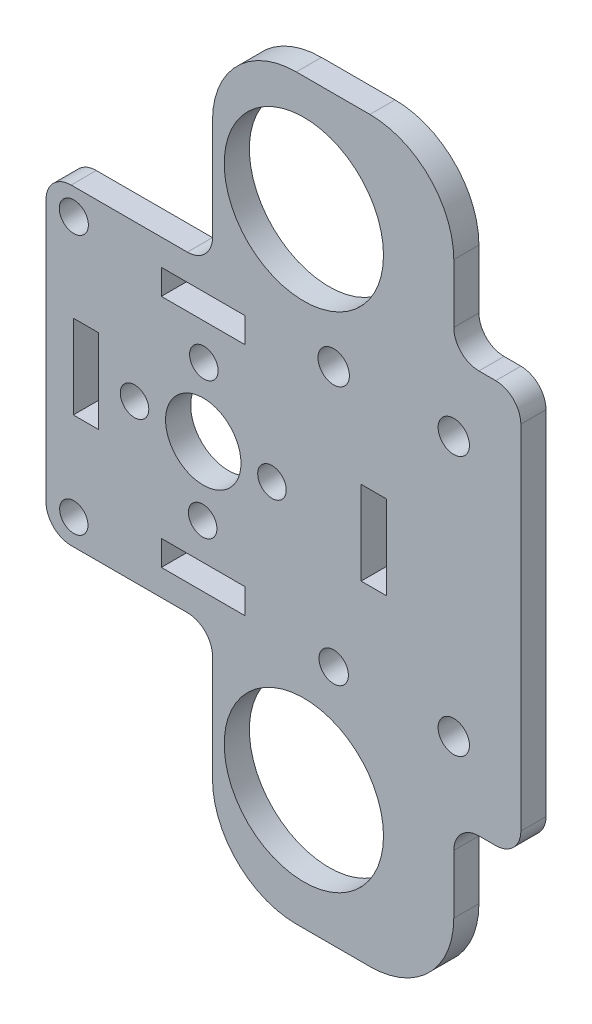
from build123d import *

# Parameters (mm, degrees)
SKETCH1_R           = 1.737885662
SKETCH1_R_2         = 1.873200063
SKETCH1_R_3         = 1.690089146
SKETCH1_R_4         = 1.754205974
SKETCH1_R_5         = 1.7
SKETCH1_R_6         = 4.5
SKETCH1_R_7         = 1.87
SKETCH1_R_8         = 9.5
SKETCH1_W           = 3
SKETCH1_H           = 10
SKETCH1_W_2         = 10
SKETCH1_H_2         = 3
BOSS_EXTRUDE1_DEPTH = 3
FILLET1_R           = 3
FILLET2_R           = 10


with BuildPart() as part:
    # Sketch1 → Boss-Extrude1 (new body)
    with BuildSketch(Plane.XY):
        Polygon((147.061964125, -92.970138098), (147.061964125, -71.856515964), (147.061964125, -67.856515964), (175.843347401, -67.856515964), (175.843347401, -87.856515964), (183.843347401, -87.856515964), (183.843347401, -135.887076434), (175.843347401, -135.887076434), (175.843347401, -155.887076434), (147.061964125, -155.887076434), (147.061964125, -151.887076434), (147.061964125, -130.215533927), (127.203791419, -130.215533927), (127.203791419, -111.591712302), (127.203791419, -92.970138098), align=None)
        with Locations((130.520049527, -96.082032258)):
            Circle(SKETCH1_R, mode=Mode.SUBTRACT)
        with Locations((161.520049527, -96.082032258)):
            Circle(SKETCH1_R_2, mode=Mode.SUBTRACT)
        with Locations((130.520049527, -127.114221831)):
            Circle(SKETCH1_R_3, mode=Mode.SUBTRACT)
        with Locations((161.520049527, -127.082032258)):
            Circle(SKETCH1_R_4, mode=Mode.SUBTRACT)
        with Locations((154.157584865, -111.662272701)):
            Circle(SKETCH1_R_5, mode=Mode.SUBTRACT)
        with Locations((145.89014032, -119.788596448)):
            Circle(SKETCH1_R_5, mode=Mode.SUBTRACT)
        with Locations((137.763816574, -111.521151903)):
            Circle(SKETCH1_R_5, mode=Mode.SUBTRACT)
        with Locations((146.031261118, -103.394828157)):
            Circle(SKETCH1_R_5, mode=Mode.SUBTRACT)
        with Locations((145.960700719, -111.591712302)):
            Circle(SKETCH1_R_6, mode=Mode.SUBTRACT)
        with Locations((175.843347401, -96.114221831)):
            Circle(SKETCH1_R_7, mode=Mode.SUBTRACT)
        with Locations((157.960700719, -81.591712302)):
            Circle(SKETCH1_R_8, mode=Mode.SUBTRACT)
        with Locations((157.960700719, -141.591712302)):
            Circle(SKETCH1_R_8, mode=Mode.SUBTRACT)
        with Locations((175.843347401, -127.114221831)):
            Circle(SKETCH1_R_7, mode=Mode.SUBTRACT)
        with Locations((131.960700719, -111.591712302)):
            Rectangle(SKETCH1_W, SKETCH1_H, mode=Mode.SUBTRACT)
        with Locations((145.960700719, -97.591712302)):
            Rectangle(SKETCH1_W_2, SKETCH1_H_2, mode=Mode.SUBTRACT)
        with Locations((145.960700719, -125.591712302)):
            Rectangle(SKETCH1_W_2, SKETCH1_H_2, mode=Mode.SUBTRACT)
        with Locations((166.293610901, -111.591712302)):
            Rectangle(SKETCH1_W, SKETCH1_H, mode=Mode.SUBTRACT)
    extrude(amount=BOSS_EXTRUDE1_DEPTH)

    # Fillet1
    fillet1_edges = [part.edges().sort_by_distance(p)[0] for p in [
        (175.843347401, -87.856515964, 1.5),
        (183.843347401, -87.856515964, 1.5),
        (183.843347401, -135.887076434, 1.5),
        (175.843347401, -135.887076434, 1.5),
        (147.061964125, -130.215533927, 1.5),
        (127.203791419, -130.215533927, 1.5),
        (127.203791419, -92.970138098, 1.5),
        (147.061964125, -92.970138098, 1.5),
    ]]
    fillet(fillet1_edges, radius=FILLET1_R)

    # Fillet2
    fillet2_edges = [part.edges().sort_by_distance(p)[0] for p in [
        (147.061964125, -67.856515964, 1.5),
        (175.843347401, -67.856515964, 1.5),
        (175.843347401, -155.887076434, 1.5),
        (147.061964125, -155.887076434, 1.5),
    ]]
    fillet(fillet2_edges, radius=FILLET2_R)


solid = part.part
